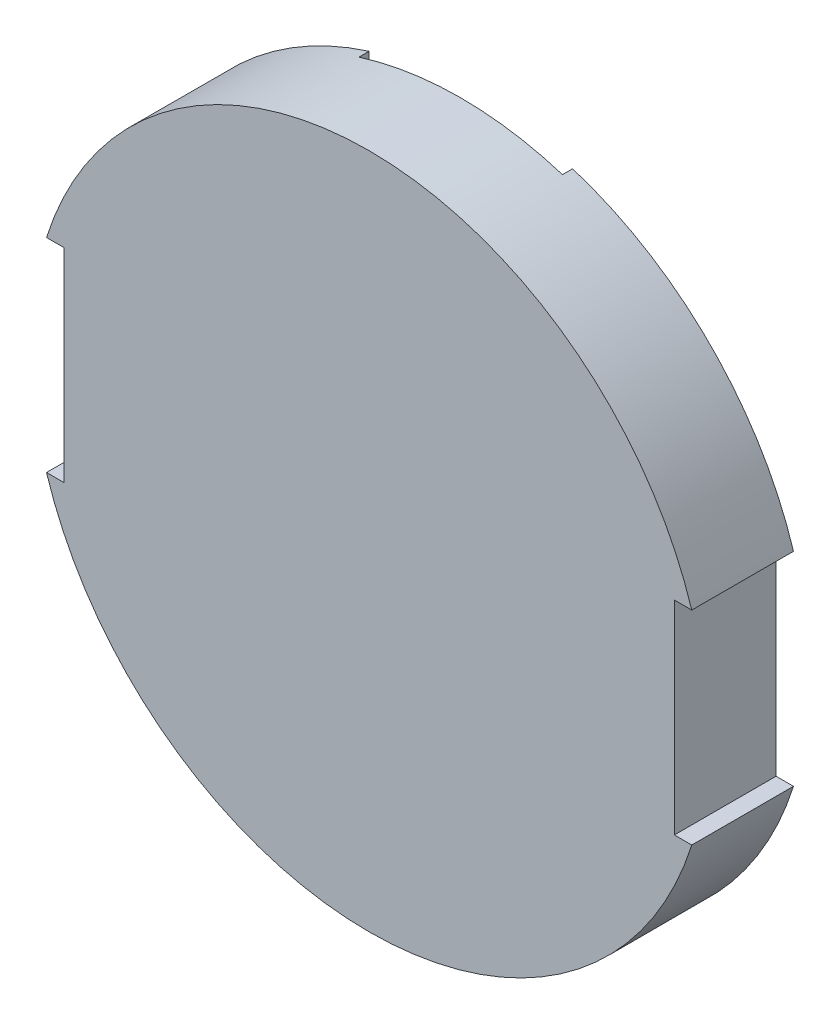
from build123d import *

# Parameters (mm, degrees)
EXTRUDE_1_DEPTH     = 20
CUT_EXTRUDE_1_DEPTH = 2


with BuildPart() as part:
    # 草圖1 → 填料-伸長1 (new body)
    with BuildSketch(Plane.XY):
        with BuildLine():
            Line((-63.421210963, 20), (-60, 20))
            Line((-60, 20), (-60, -20))
            Line((-60, -20), (-63.421210963, -20))
            ThreePointArc((-63.421210963, -20), (0, -66.5), (63.421210963, -20))
            Line((63.421210963, -20), (60, -20))
            Line((60, -20), (60, 20))
            Line((60, 20), (63.421210963, 20))
            ThreePointArc((63.421210963, 20), (0, 66.5), (-63.421210963, 20))
        make_face()
    extrude(amount=EXTRUDE_1_DEPTH)

    # 草圖2 → 除料-伸長1 (cut)
    with BuildSketch(Plane(origin=(0, 0, 0), x_dir=(-1, 0, 0), z_dir=(0, 0, -1))):
        with BuildLine():
            Line((-20, 63.421210963), (-20, -63.421210963))
            ThreePointArc((-20, -63.421210963), (0, -66.5), (20, -63.421210963))
            Line((20, -63.421210963), (20, 63.421210963))
            ThreePointArc((20, 63.421210963), (0, 66.5), (-20, 63.421210963))
        make_face()
    extrude(amount=-CUT_EXTRUDE_1_DEPTH, mode=Mode.SUBTRACT)


solid = part.part
